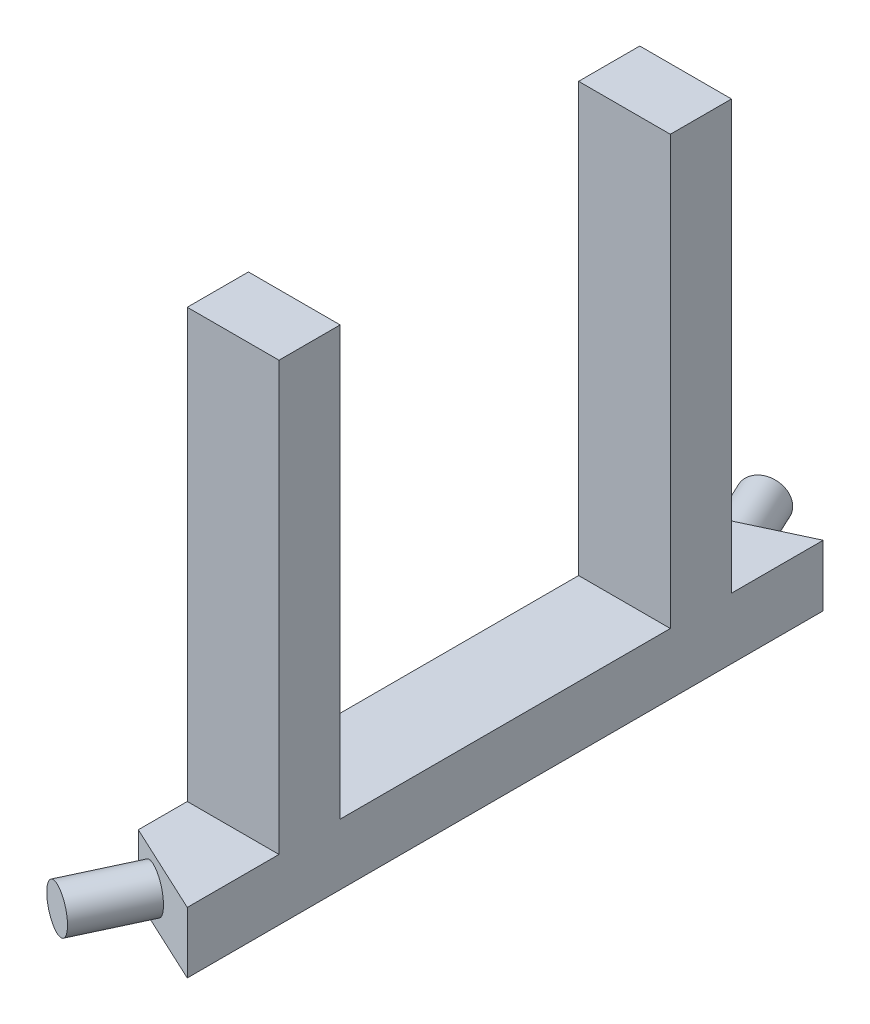
from build123d import *

# Parameters (mm, degrees)
SKETCH1_W           = 38.1
SKETCH1_H           = 25.4
BOSS_EXTRUDE1_DEPTH = 132.08
SKETCH5_W           = 38.1
SKETCH5_H           = 25.4
BOSS_EXTRUDE3_DEPTH = 177.8
CUT_EXTRUDE1_DEPTH  = 25.4
SKETCH3_R           = 8.89
BOSS_EXTRUDE2_DEPTH = 30


with BuildPart() as part:
    # Sketch1 → Boss-Extrude1 (new body)
    with BuildSketch(Plane.XY):
        with Locations((19.05, 12.7)):
            Rectangle(SKETCH1_W, SKETCH1_H)
    boss_extrude1 = extrude(amount=BOSS_EXTRUDE1_DEPTH)

    # Sketch5 → Boss-Extrude3 (add)
    with BuildSketch(Plane(origin=(0, 25.4, 0), x_dir=(1, 0, 0), z_dir=(0, 1, 0))):
        with Locations((19.05, -81.28)):
            Rectangle(SKETCH5_W, SKETCH5_H)
    boss_extrude3 = extrude(amount=BOSS_EXTRUDE3_DEPTH)

    # Sketch2 → Cut-Extrude1 (cut)
    with BuildSketch(Plane(origin=(0, 25.4, 0), x_dir=(1, 0, 0), z_dir=(0, 1, 0))):
        Polygon((-12.106033358, -108.66854216), (38.1, -132.08), (54.824729612, -172.409676007), (-49.386286867, -161.765658866), align=None)
    cut_extrude1 = extrude(amount=-CUT_EXTRUDE1_DEPTH, mode=Mode.SUBTRACT)

    # Mirror2: Boss-Extrude1, Boss-Extrude3, Cut-Extrude1 across plane
    add(boss_extrude1.mirror(Plane(origin=(0, 0, 0), x_dir=(1, 0, 0), z_dir=(0, 0, -1))))
    add(boss_extrude3.mirror(Plane(origin=(0, 0, 0), x_dir=(1, 0, 0), z_dir=(0, 0, -1))))
    add(cut_extrude1.mirror(Plane(origin=(0, 0, 0), x_dir=(1, 0, 0), z_dir=(0, 0, -1))), mode=Mode.SUBTRACT)

    # Sketch3 → Boss-Extrude2 (add)
    with BuildSketch(Plane(origin=(-43.784678988, 0, 93.896547102), x_dir=(0.906307787, 0, 0.422618262), z_dir=(-0.422618262, 0, 0.906307787))):
        with Locations((61.011047984, 12.7)):
            Circle(SKETCH3_R)
    boss_extrude2 = extrude(amount=BOSS_EXTRUDE2_DEPTH)

    # Mirror3: Boss-Extrude2 across plane
    add(boss_extrude2.mirror(Plane.XY))


solid = part.part
